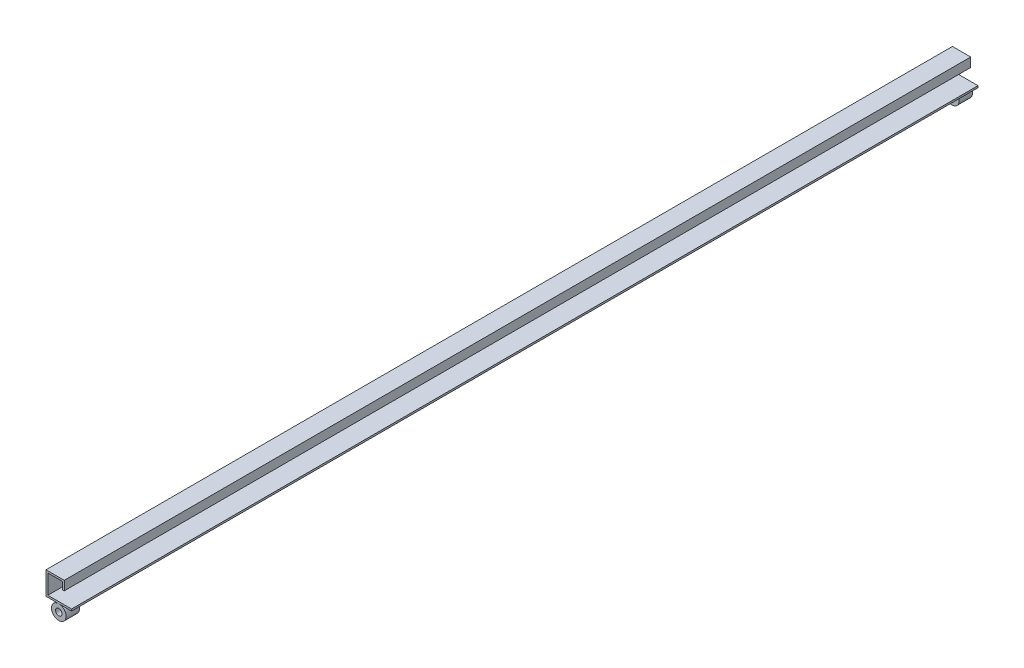
from build123d import *

# Parameters (mm, degrees)
BOSS_EXTRUDE1_DEPTH = 993
SKETCH2_R           = 8
SKETCH2_R_2         = 3.5
BOSS_EXTRUDE2_DEPTH = 14.6


with BuildPart() as part:
    # Sketch1 → Boss-Extrude1 (new body)
    with BuildSketch(Plane.XY):
        Polygon((0, 0), (-28, 0), (-28, 25.2), (-8, 25.2), (-8, 15.2), (-10, 15.2), (-10, 23.2), (-26, 23.2), (-26, 2), (0, 2), align=None)
    extrude(amount=BOSS_EXTRUDE1_DEPTH)


with BuildPart() as body_2:
    # Sketch2 → Boss-Extrude2 (new body)
    with BuildSketch(Plane(origin=(0, 0, 0), x_dir=(-1, 0, 0), z_dir=(0, 0, -1))):
        with Locations((14, -8)):
            Circle(SKETCH2_R)
        with Locations((14, -8)):
            Circle(SKETCH2_R_2, mode=Mode.SUBTRACT)
    extrude(amount=-BOSS_EXTRUDE2_DEPTH)


with BuildPart() as body_3:
    # Mirror10: mirrored copy
    add(body_2.part.mirror(Plane(origin=(0, 0, 496.5), x_dir=(1, 0, 0), z_dir=(0, 0, -1))))


solid = Compound([part.part, body_2.part, body_3.part])
